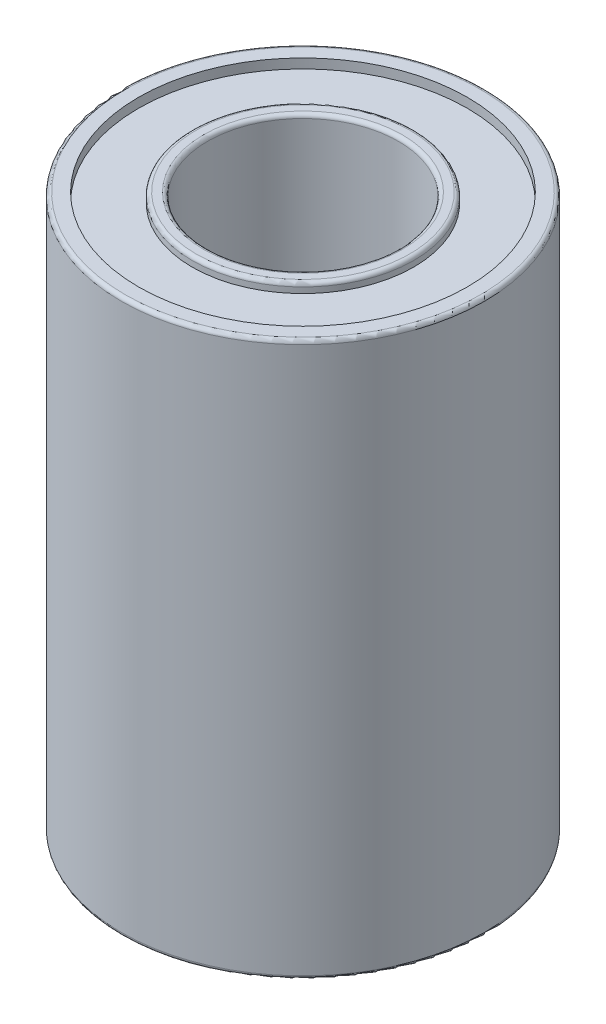
from build123d import *

# Parameters (mm, degrees)
SKETCH1_R           = 9.5
SKETCH1_R_2         = 5
BOSS_EXTRUDE1_DEPTH = 29
SKETCH2_R           = 8.6
SKETCH2_R_2         = 5.8
CUT_EXTRUDE1_DEPTH  = 0.5
SKETCH3_R           = 8.6
SKETCH3_R_2         = 5.8
CUT_EXTRUDE2_DEPTH  = 0.5
FILLET1_R           = 0.2


with BuildPart() as part:
    # Sketch1 → Boss-Extrude1 (new body)
    with BuildSketch(Plane(origin=(0, 0, 0), x_dir=(1, 0, 0), z_dir=(0, 1, 0))):
        Circle(SKETCH1_R)
        Circle(SKETCH1_R_2, mode=Mode.SUBTRACT)
    extrude(amount=BOSS_EXTRUDE1_DEPTH)

    # Sketch2 → Cut-Extrude1 (cut)
    with BuildSketch(Plane(origin=(0, 29, 0), x_dir=(1, 0, 0), z_dir=(0, 1, 0))):
        Circle(SKETCH2_R)
        Circle(SKETCH2_R_2, mode=Mode.SUBTRACT)
    extrude(amount=-CUT_EXTRUDE1_DEPTH, mode=Mode.SUBTRACT)

    # Sketch3 → Cut-Extrude2 (cut)
    with BuildSketch(Plane.XZ):
        Circle(SKETCH3_R)
        Circle(SKETCH3_R_2, mode=Mode.SUBTRACT)
    extrude(amount=-CUT_EXTRUDE2_DEPTH, mode=Mode.SUBTRACT)

    # Fillet1
    fillet1_edges = [part.edges().sort_by_distance(p)[0] for p in [
        (-9.5, 0, 0),
        (-9.5, 29, 0),
        (-8.6, 0, 0),
        (-5.8, 0, 0),
        (-5.8, 29, 0),
        (-5, 0, 0),
        (-5, 29, 0),
    ]]
    fillet(fillet1_edges, radius=FILLET1_R)


solid = part.part
